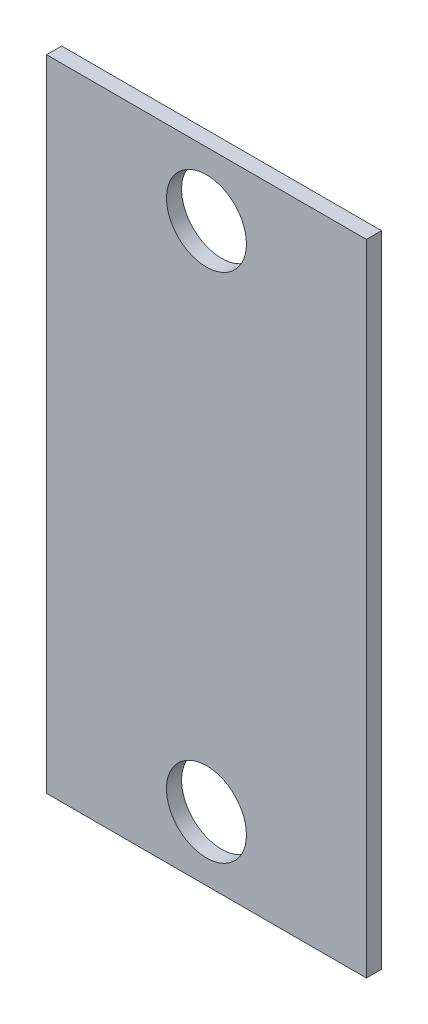
from build123d import *

# Parameters (mm, degrees)
SKETCH1_W           = 63.5
SKETCH1_H           = 127
SKETCH1_R           = 7.9375
BOSS_EXTRUDE2_DEPTH = 2.9972


with BuildPart() as part:
    # Sketch1 → Boss-Extrude2 (new body)
    with BuildSketch(Plane.XY):
        with Locations((31.75, -63.5)):
            Rectangle(SKETCH1_W, SKETCH1_H)
        with Locations((31.75, -114.3)):
            Circle(SKETCH1_R, mode=Mode.SUBTRACT)
        with Locations((31.75, -12.7)):
            Circle(SKETCH1_R, mode=Mode.SUBTRACT)
    extrude(amount=BOSS_EXTRUDE2_DEPTH)


solid = part.part
